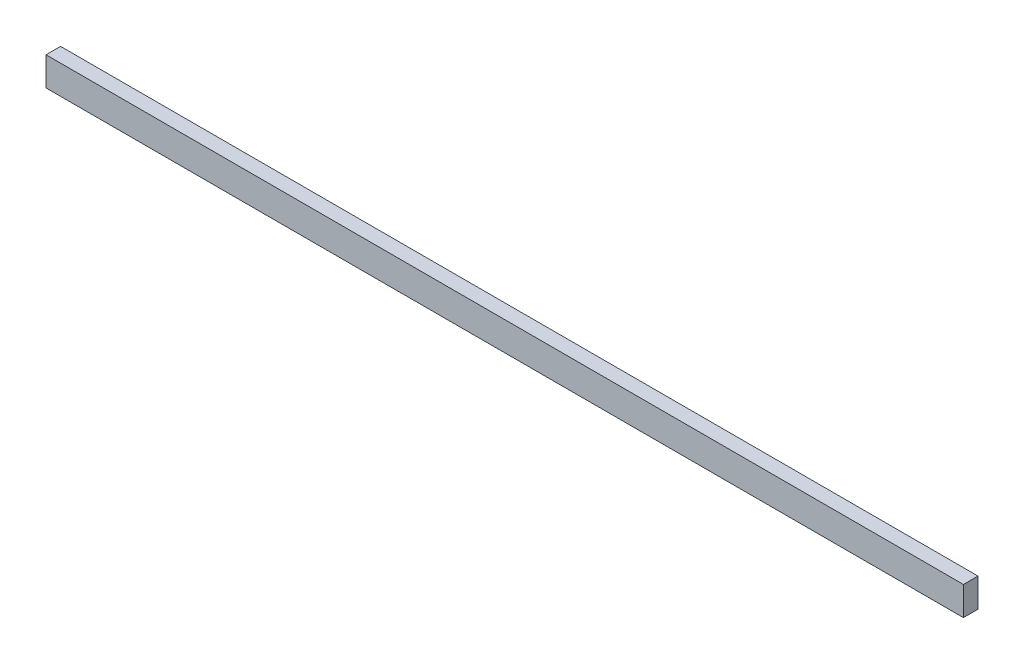
from build123d import *

# Parameters (mm, degrees)
SKETCH1_W           = 6.0452
SKETCH1_H           = 11.938
BOSS_EXTRUDE1_DEPTH = 190.5


with BuildPart() as part:
    # Sketch1 → Boss-Extrude1 (new body, symmetric)
    with BuildSketch(Plane(origin=(0, 0, 0), x_dir=(0, 0, -1), z_dir=(1, 0, 0))):
        Rectangle(SKETCH1_W, SKETCH1_H)
    extrude(amount=BOSS_EXTRUDE1_DEPTH, both=True)


solid = part.part
